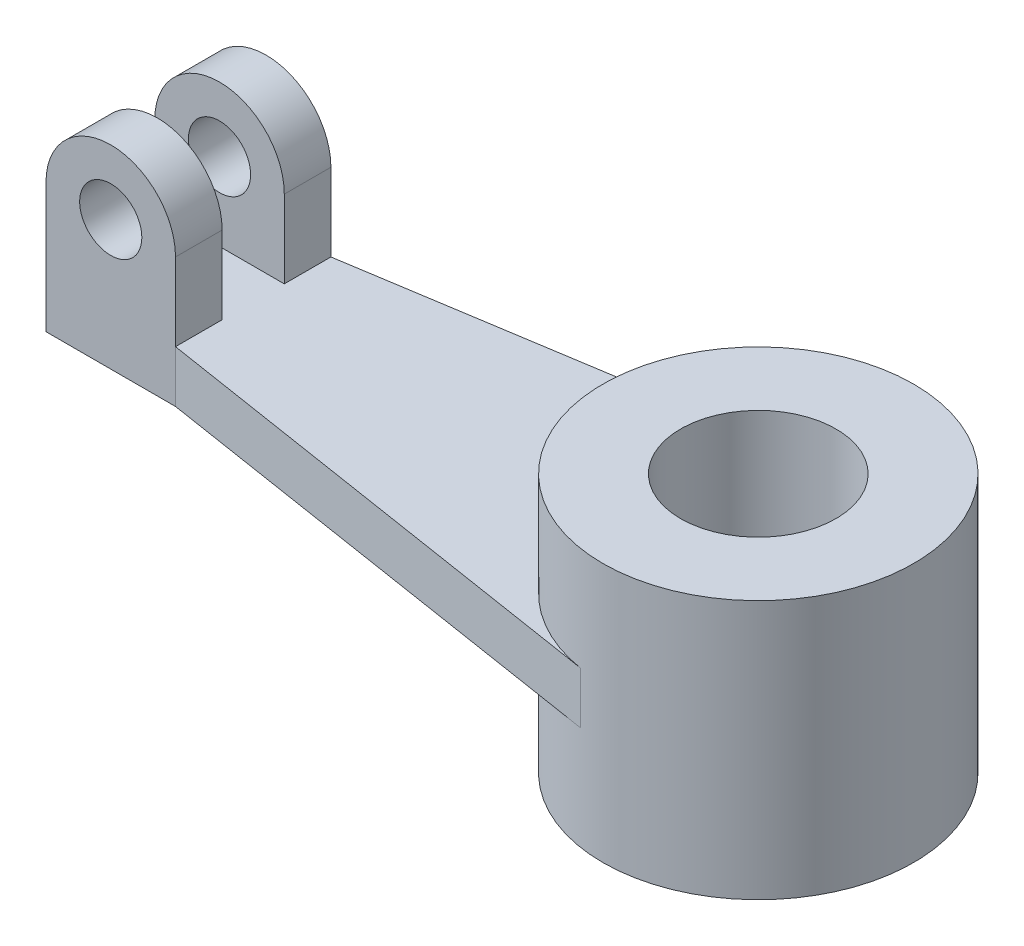
from build123d import *

# Parameters (mm, degrees)
BOSS_EXTRUDE2_DEPTH = 5
SKETCH7_R           = 30
BOSS_EXTRUDE3_DEPTH = 25
SKETCH8_R           = 15
CUT_EXTRUDE2_DEPTH  = 50
BOSS_EXTRUDE4_DEPTH = 9
SKETCH10_R          = 6
CUT_EXTRUDE3_DEPTH  = 9
BOSS_EXTRUDE5_DEPTH = 9
SKETCH12_R          = 6
CUT_EXTRUDE4_DEPTH  = 9


with BuildPart() as part:
    # Sketch6 → Boss-Extrude2 (new body, symmetric)
    with BuildSketch(Plane(origin=(0, 0, 0), x_dir=(1, 0, 0), z_dir=(0, 1, 0))):
        with BuildLine():
            Line((-30, 0), (-122.5, 0))
            Line((-122.5, 0), (-122.5, -15))
            Line((-122.5, -15), (-97.5, -15))
            Line((-97.5, -15), (-4.671688756, -29.634023084))
            ThreePointArc((-4.671688756, -29.634023084), (-22.805160191, -19.491656386), (-30, 0))
        make_face()
    boss_extrude2 = extrude(amount=BOSS_EXTRUDE2_DEPTH, both=True)

    # Sketch7 → Boss-Extrude3 (add, symmetric)
    with BuildSketch(Plane(origin=(0, 0, 0), x_dir=(1, 0, 0), z_dir=(0, 1, 0))):
        with Locations(Location((0, 0, 0), (0, 0, 270))):  # turned: the seam where the file's is
            Circle(SKETCH7_R)
    extrude(amount=BOSS_EXTRUDE3_DEPTH, both=True)

    # Sketch8 → Cut-Extrude2 (cut)
    with BuildSketch(Plane(origin=(0, 25, 0), x_dir=(1, 0, 0), z_dir=(0, 1, 0))):
        with Locations(Location((0, 0, 0), (0, 0, 270))):  # turned: the seam where the file's is
            Circle(SKETCH8_R)
    extrude(amount=-CUT_EXTRUDE2_DEPTH, mode=Mode.SUBTRACT)

    # Mirror1: Boss-Extrude2 across plane
    add(boss_extrude2.mirror(Plane(origin=(0, 5, 0), x_dir=(1, 0, 0), z_dir=(0, 0, -1))))

    # Sketch9 → Boss-Extrude4 (add)
    with BuildSketch(Plane.XY.offset(15)):
        with BuildLine():
            Line((-122.5, 5), (-97.5, 5))
            Line((-97.5, 5), (-97.5, 20))
            ThreePointArc((-97.5, 20), (-110, 32.5), (-122.5, 20))
            Line((-122.5, 20), (-122.5, 5))
        make_face()
    extrude(amount=-BOSS_EXTRUDE4_DEPTH)

    # Sketch10 → Cut-Extrude3 (cut)
    with BuildSketch(Plane.XY.offset(15)):
        with Locations((-110, 20)):
            Circle(SKETCH10_R)
    extrude(amount=-CUT_EXTRUDE3_DEPTH, mode=Mode.SUBTRACT)

    # Sketch11 → Boss-Extrude5 (add)
    with BuildSketch(Plane(origin=(0, 0, -15), x_dir=(-1, 0, 0), z_dir=(0, 0, -1))):
        with BuildLine():
            Line((122.5, 5), (97.5, 5))
            Line((97.5, 5), (97.5, 20))
            ThreePointArc((97.5, 20), (110, 32.5), (122.5, 20))
            Line((122.5, 20), (122.5, 5))
        make_face()
    extrude(amount=-BOSS_EXTRUDE5_DEPTH)

    # Sketch12 → Cut-Extrude4 (cut)
    with BuildSketch(Plane(origin=(0, 0, -15), x_dir=(-1, 0, 0), z_dir=(0, 0, -1))):
        with Locations(Location((110, 20, 0), (0, 0, 180))):  # turned: the seam where the file's is
            Circle(SKETCH12_R)
    extrude(amount=-CUT_EXTRUDE4_DEPTH, mode=Mode.SUBTRACT)


solid = part.part
